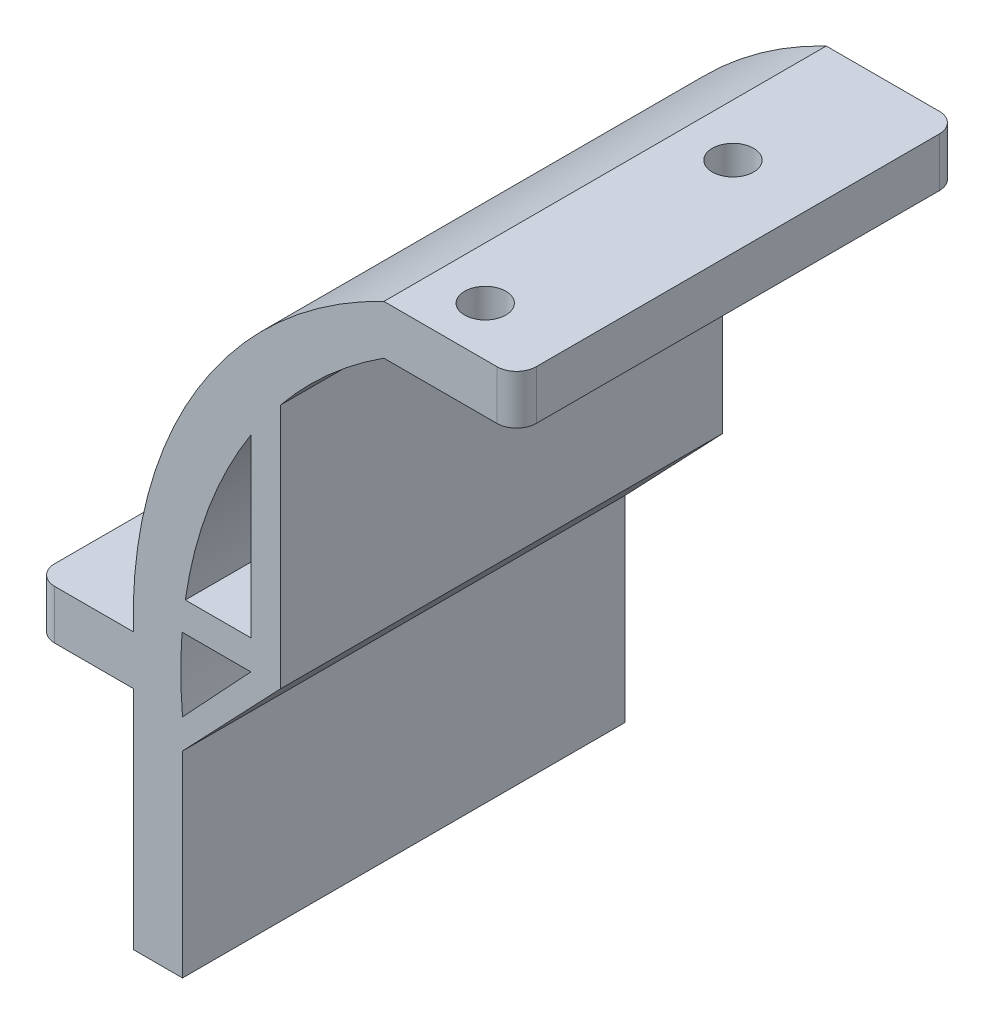
from build123d import *

# Parameters (mm, degrees)
SKETCH3_W           = 13.5
SKETCH3_H           = 5
SKETCH3_W_2         = 10
SKETCH3_W_3         = 5
SKETCH3_H_2         = 23
BOSS_EXTRUDE1_DEPTH = 45
FILLET1_R           = 2
SKETCH5_R           = 2.1
CUT_EXTRUDE2_DEPTH  = 45
SKETCH6_R           = 2.1
CUT_EXTRUDE3_DEPTH  = 45
BOSS_EXTRUDE3_DEPTH = 45
BOSS_EXTRUDE4_DEPTH = 45


with BuildPart() as part:
    # Sketch3 → Boss-Extrude1 (new body)
    with BuildSketch(Plane.XY):
        with BuildLine():
            ThreePointArc((-5.06519953, 257.264696919), (-21.146881422, 239.197551787), (-25.551614771, 215.414352888))
            Line((-25.551614771, 215.414352888), (-30.551614771, 215.414352888))
            Line((-30.551614771, 215.414352888), (-30.551614771, 220.414352888))
            ThreePointArc((-30.551614771, 220.414352888), (-24.004098535, 245.112635185), (-5.06519953, 262.264696919))
            Line((-5.06519953, 262.264696919), (-5.06519953, 257.264696919))
        make_face()
        with Locations((1.68480047, 259.764696919)):
            Rectangle(SKETCH3_W, SKETCH3_H)
        with Locations((-35.551614771, 217.914352888)):
            Rectangle(SKETCH3_W_2, SKETCH3_H)
        with Locations((-28.051614771, 203.914352888)):
            Rectangle(SKETCH3_W_3, SKETCH3_H_2)
    extrude(amount=BOSS_EXTRUDE1_DEPTH)

    # Fillet1
    fillet1_edges = [part.edges().sort_by_distance(p)[0] for p in [
        (-40.551614771, 217.914352888, 0),
        (8.43480047, 259.764696919, 45),
        (8.43480047, 259.764696919, 0),
        (-40.551614771, 217.914352888, 45),
    ]]
    fillet(fillet1_edges, radius=FILLET1_R)

    # Sketch5 → Cut-Extrude2 (cut)
    with BuildSketch(Plane(origin=(0, 262.264696919, 0), x_dir=(1, 0, 0), z_dir=(0, 1, 0))):
        with Locations((0.24480047, -40)):
            Circle(SKETCH5_R)
        with Locations((0.24480047, -14.8)):
            Circle(SKETCH5_R)
    extrude(amount=-CUT_EXTRUDE2_DEPTH, mode=Mode.SUBTRACT)

    # Sketch6 → Cut-Extrude3 (cut)
    with BuildSketch(Plane(origin=(0, 220.414352888, 0), x_dir=(1, 0, 0), z_dir=(0, 1, 0))):
        with Locations((-35.551614771, -10)):
            Circle(SKETCH6_R)
        with Locations((-35.551614771, -35)):
            Circle(SKETCH6_R)
    extrude(amount=-CUT_EXTRUDE3_DEPTH, mode=Mode.SUBTRACT)

    # Sketch7 → Boss-Extrude3 (add, through all)
    with BuildSketch(Plane.XY.offset(45)):
        with BuildLine():
            Line((-15.597369426, 247.859750777), (-15.597369426, 222.859750777))
            Line((-15.597369426, 222.859750777), (-25.597369426, 222.859750777))
            ThreePointArc((-25.597369426, 222.859750777), (-25.456525287, 224.362535182), (-25.265361734, 225.859750777))
            Line((-25.265361734, 225.859750777), (-18.597369426, 225.859750777))
            Line((-18.597369426, 225.859750777), (-18.597369426, 243.72377838))
            ThreePointArc((-18.597369426, 243.72377838), (-17.156118075, 245.834377519), (-15.597369426, 247.859750777))
        make_face()
    extrude(amount=-BOSS_EXTRUDE3_DEPTH)

    # Sketch8 → Boss-Extrude4 (add, through all)
    with BuildSketch(Plane.XY.offset(45)):
        Polygon((-15.597369426, 222.859750777), (-25.551614771, 212.414352888), (-25.551614771, 215.414352888), (-18.597369426, 222.859750777), align=None)
    extrude(amount=-BOSS_EXTRUDE4_DEPTH)


solid = part.part
